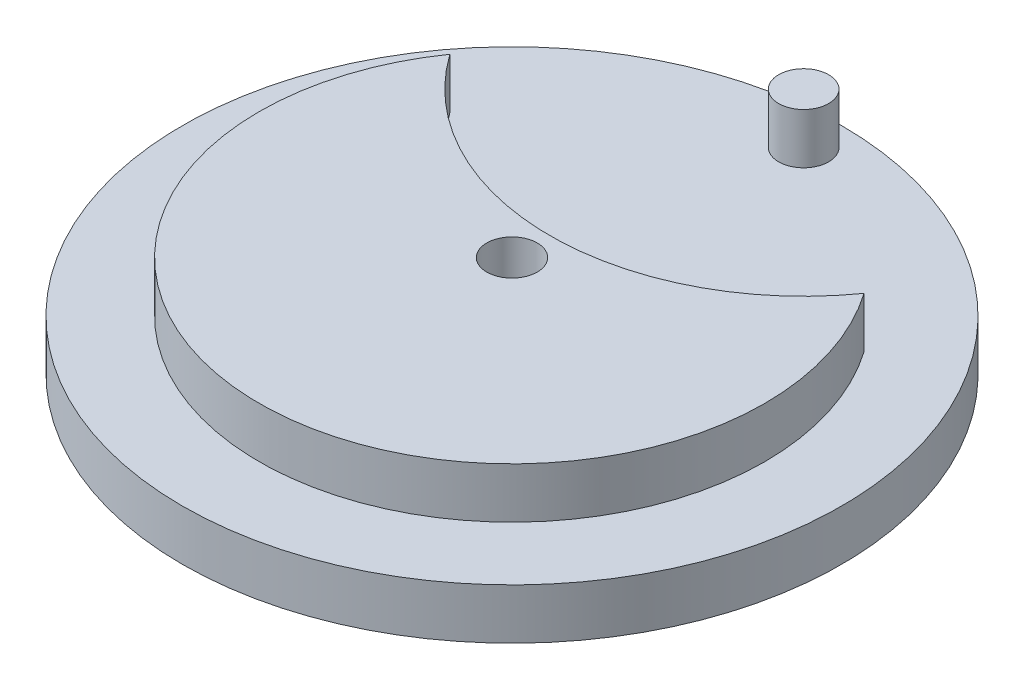
from build123d import *

# Parameters (mm, degrees)
SKETCH1_R           = 65.235026919
SKETCH1_R_2         = 4.95
BOSS_EXTRUDE4_DEPTH = 10
SKETCH1_5_R         = 4.95
SKETCH1_5_R_2       = 5
BOSS_EXTRUDE5_DEPTH = 20


with BuildPart() as part:
    # Sketch1 → Boss-Extrude4 (new body)
    with BuildSketch(Plane(origin=(0, 0, 0), x_dir=(1, 0, 0), z_dir=(0, 1, 0))):
        with Locations(Location((0, 0, 0), (0, 0, 270))):  # turned: the seam where the file's is
            Circle(SKETCH1_R)
        with Locations(Location((0, 57.735026919, 0), (0, 0, 270))):  # turned: the seam where the file's is
            Circle(SKETCH1_R_2, mode=Mode.SUBTRACT)
        with BuildLine():
            ThreePointArc((-40.989114073, 28.69280839), (0, -50.033835809), (40.989114073, 28.69280839))
            ThreePointArc((40.989114073, 28.69280839), (0, 7.5), (-40.989114073, 28.69280839))
        make_face(mode=Mode.SUBTRACT)
    extrude(amount=BOSS_EXTRUDE4_DEPTH)

    # Sketch1_5 → Boss-Extrude5 (add)
    with BuildSketch(Plane(origin=(0, 0, 0), x_dir=(1, 0, 0), z_dir=(0, 1, 0))):
        with Locations(Location((0, 57.735026919, 0), (0, 0, 270))):  # turned: the seam where the file's is
            Circle(SKETCH1_5_R)
        with BuildLine():
            ThreePointArc((-40.989114073, 28.69280839), (0, -50.033835809), (40.989114073, 28.69280839))
            ThreePointArc((40.989114073, 28.69280839), (0, 7.5), (-40.989114073, 28.69280839))
        make_face()
        with Locations(Location((0, 0, 0), (0, 0, 270))):  # turned: the seam where the file's is
            Circle(SKETCH1_5_R_2, mode=Mode.SUBTRACT)
    extrude(amount=BOSS_EXTRUDE5_DEPTH)


solid = part.part
